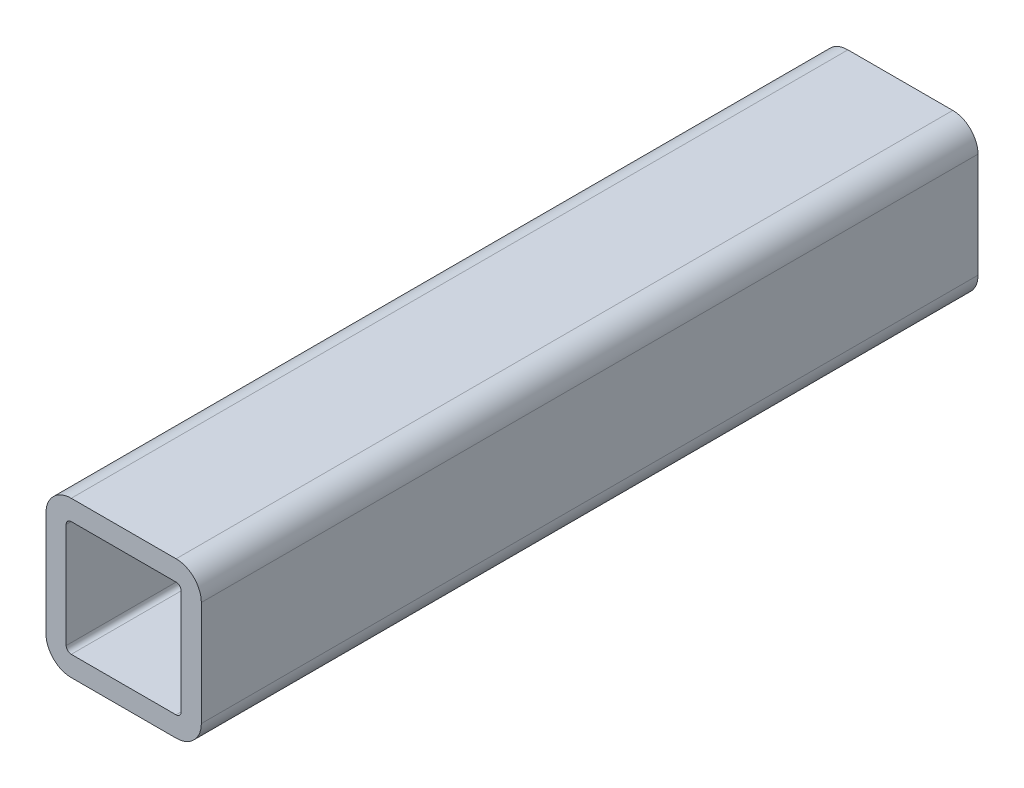
from build123d import *

# Parameters (mm, degrees)
BOSS_EXTRUDE1_DEPTH = 31.75


with BuildPart() as part:
    # Sketch4 → Boss-Extrude1 (new body, symmetric)
    with BuildSketch(Plane.XY):
        with BuildLine():
            Line((6.35, -4.28625), (6.35, 4.28625))
            ThreePointArc((6.35, 4.28625), (5.74554162, 5.74554162), (4.28625, 6.35))
            Line((4.28625, 6.35), (-4.28625, 6.35))
            ThreePointArc((-4.28625, 6.35), (-5.74554162, 5.74554162), (-6.35, 4.28625))
            Line((-6.35, 4.28625), (-6.35, -4.28625))
            ThreePointArc((-6.35, -4.28625), (-5.74554162, -5.74554162), (-4.28625, -6.35))
            Line((-4.28625, -6.35), (4.28625, -6.35))
            ThreePointArc((4.28625, -6.35), (5.74554162, -5.74554162), (6.35, -4.28625))
        make_face()
        with BuildLine():
            Line((4.699, 4.28625), (4.699, -4.28625))
            ThreePointArc((4.699, -4.28625), (4.578108324, -4.578108324), (4.28625, -4.699))
            Line((4.28625, -4.699), (-4.28625, -4.699))
            ThreePointArc((-4.28625, -4.699), (-4.578108324, -4.578108324), (-4.699, -4.28625))
            Line((-4.699, -4.28625), (-4.699, 4.28625))
            ThreePointArc((-4.699, 4.28625), (-4.578108324, 4.578108324), (-4.28625, 4.699))
            Line((-4.28625, 4.699), (4.28625, 4.699))
            ThreePointArc((4.28625, 4.699), (4.578108324, 4.578108324), (4.699, 4.28625))
        make_face(mode=Mode.SUBTRACT)
    extrude(amount=BOSS_EXTRUDE1_DEPTH, both=True)


solid = part.part
